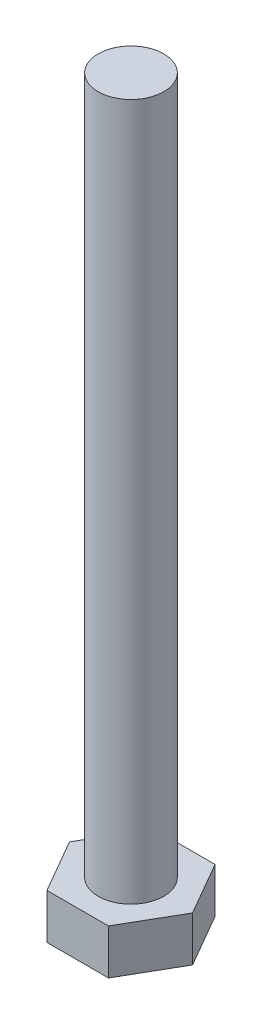
from build123d import *

# Parameters (mm, degrees)
BOSS_EXTRUDE1_DEPTH = 5.5
SKETCH3_R           = 4
BOSS_EXTRUDE2_DEPTH = 85


with BuildPart() as part:
    # Sketch2 → Boss-Extrude1 (new body)
    with BuildSketch(Plane(origin=(0, 0, 0), x_dir=(1, 0, 0), z_dir=(0, 1, 0))):
        Polygon((-7.505553499, 0), (-3.75277675, -6.5), (3.75277675, -6.5), (7.505553499, 0), (3.75277675, 6.5), (-3.75277675, 6.5), align=None)
    extrude(amount=BOSS_EXTRUDE1_DEPTH)

    # Sketch3 → Boss-Extrude2 (add)
    with BuildSketch(Plane(origin=(0, 5.5, 0), x_dir=(1, 0, 0), z_dir=(0, 1, 0))):
        Circle(SKETCH3_R)
    extrude(amount=BOSS_EXTRUDE2_DEPTH)


solid = part.part
